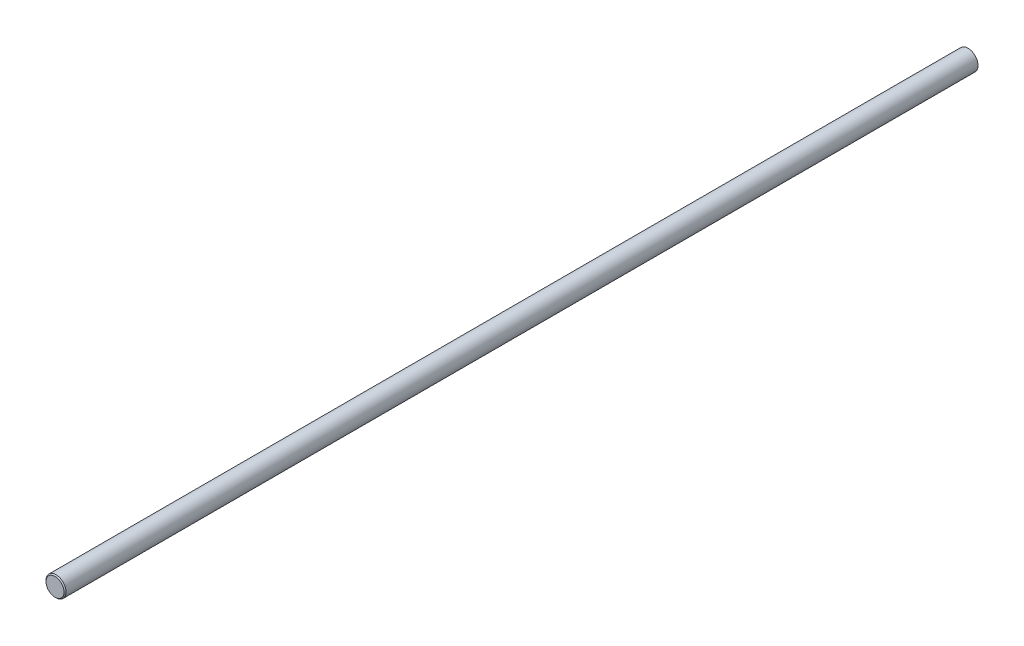
from build123d import *


with BuildPart() as part:
    # Esboço1 → Revolução1 (revolve)
    with BuildSketch(Plane(origin=(0, 0, 0), x_dir=(1, 0, 0), z_dir=(0, 1, 0))):
        Polygon((15.48, -1501.5875), (0, -1501.5875), (0, -1525.5), (15.075, -1525.5), (16.75, -1523.825), (16.75, 0), (15.48, 0), align=None)
    revolve(axis=Axis((0, 0, 0), (0, 0, 1)))


solid = part.part
